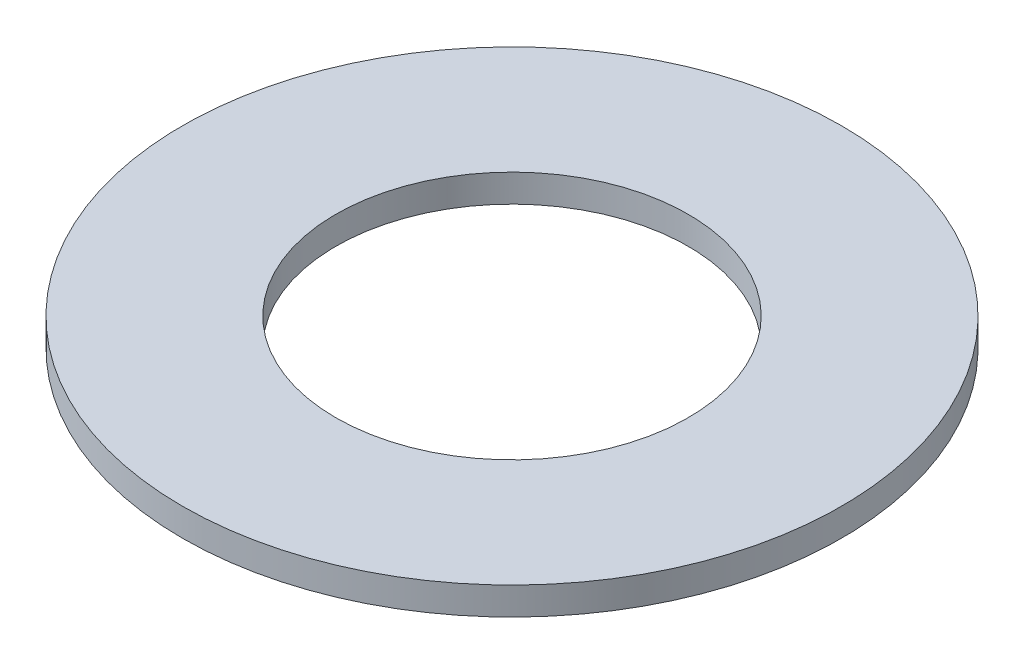
from build123d import *

# Parameters (mm, degrees)
SKETCH1_R           = 4.75
BOSS_EXTRUDE1_DEPTH = 0.4
SKETCH2_R           = 2.54
CUT_EXTRUDE1_DEPTH  = 0.4


with BuildPart() as part:
    # Sketch1 → Boss-Extrude1 (new body)
    with BuildSketch(Plane(origin=(0, 0, 0), x_dir=(1, 0, 0), z_dir=(0, 1, 0))):
        Circle(SKETCH1_R)
    extrude(amount=BOSS_EXTRUDE1_DEPTH)

    # Sketch2 → Cut-Extrude1 (cut)
    with BuildSketch(Plane(origin=(0, 0.4, 0), x_dir=(1, 0, 0), z_dir=(0, 1, 0))):
        Circle(SKETCH2_R)
    extrude(amount=-CUT_EXTRUDE1_DEPTH, mode=Mode.SUBTRACT)


solid = part.part
